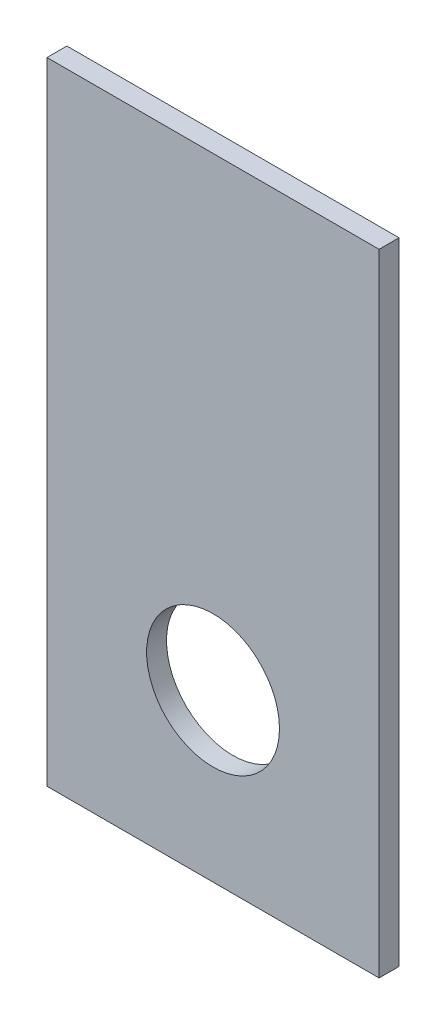
from build123d import *

# Parameters (mm, degrees)
SKETCH1_W           = 50
SKETCH1_H           = 95
SKETCH1_R           = 10
BOSS_EXTRUDE1_DEPTH = 3


with BuildPart() as part:
    # Sketch1 → Boss-Extrude1 (new body)
    with BuildSketch(Plane.XY):
        with Locations((0, 47.5)):
            Rectangle(SKETCH1_W, SKETCH1_H)
        with Locations((0, 25)):
            Circle(SKETCH1_R, mode=Mode.SUBTRACT)
    extrude(amount=BOSS_EXTRUDE1_DEPTH)


solid = part.part
